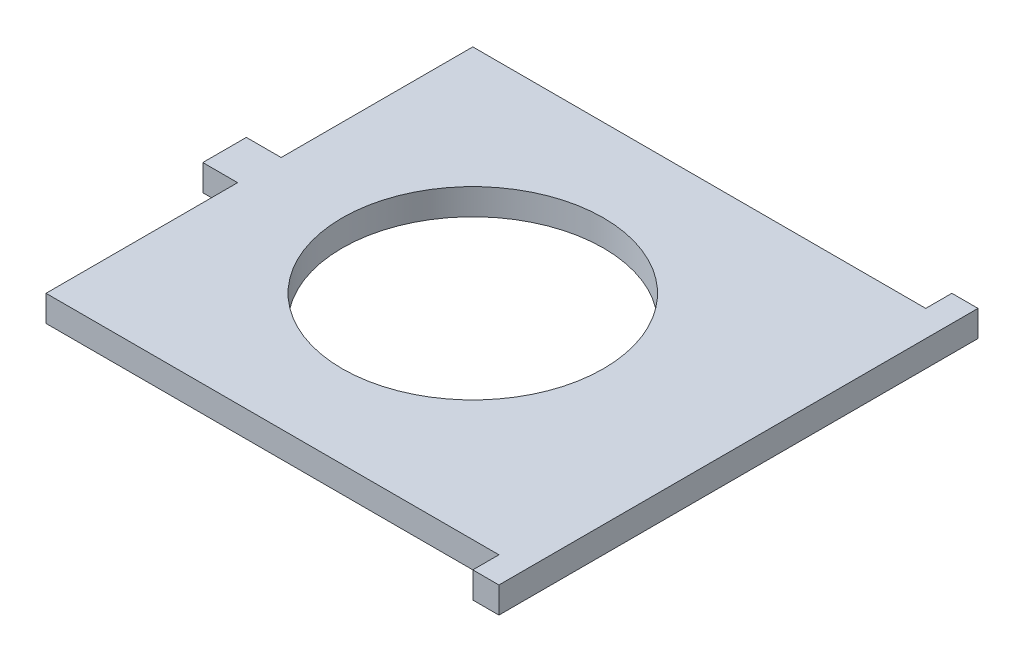
from build123d import *

# Parameters (mm, degrees)
SKETCH1_W           = 49
SKETCH1_H           = 49
SKETCH1_R           = 15
SKETCH1_W_2         = 4
SKETCH1_H_2         = 5
SKETCH1_W_3         = 3
BOSS_EXTRUDE1_DEPTH = 3


with BuildPart() as part:
    # Sketch1 → Boss-Extrude1 (new body)
    with BuildSketch(Plane(origin=(0, 0, 0), x_dir=(1, 0, 0), z_dir=(0, 1, 0))):
        Rectangle(SKETCH1_W, SKETCH1_H)
        Circle(SKETCH1_R, mode=Mode.SUBTRACT)
        with Locations((-26.5, 0)):
            Rectangle(SKETCH1_W_2, SKETCH1_H_2)
        with Locations((26, 0)):
            Rectangle(SKETCH1_W_3, SKETCH1_H)
        Polygon((30.5, 27.5), (27.5, 27.5), (27.5, 24.5), (27.5, -24.5), (27.5, -27.5), (30.5, -27.5), align=None)
    extrude(amount=BOSS_EXTRUDE1_DEPTH)


solid = part.part
